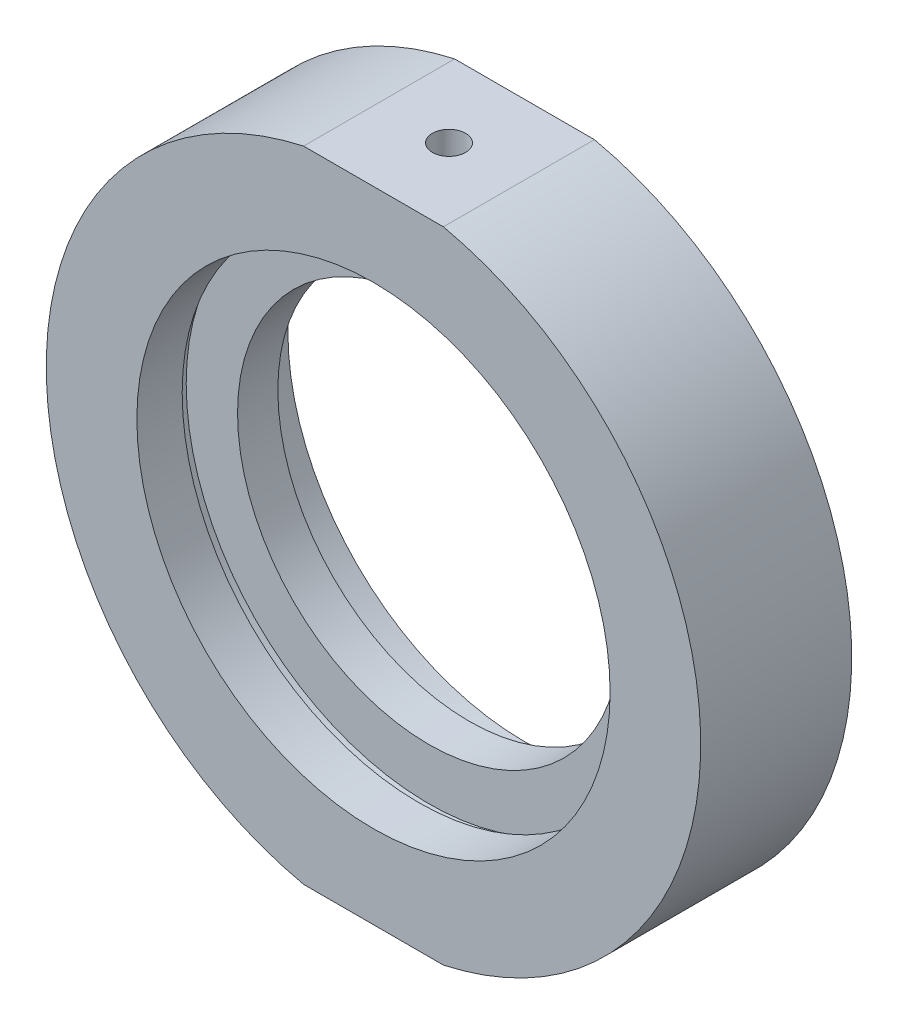
from build123d import *

# Parameters (mm, degrees)
SKETCH_2_W             = 64.02174429
SKETCH_2_H             = 9.248919907
CUT_EXTRUDE_1_DEPTH    = 49
HOLE_WIZARD_M4_2_D     = 3.3
HOLE_WIZARD_M4_2_DEPTH = 5.5
HOLE_WIZARD_M4_2_TIP   = 0.991420021
HOLE_WIZARD_M6_2_D     = 5
HOLE_WIZARD_M6_2_DEPTH = 5.5
HOLE_WIZARD_M6_2_TIP   = 1.502151548


with BuildPart() as part:
    # 草图1 → 旋转1 (revolve)
    with BuildSketch(Plane(origin=(0, 0, 0), x_dir=(1, 0, 0), z_dir=(0, 1, 0)), mode=Mode.PRIVATE) as revolve_1_sk:
        Polygon((32.5, 7.5), (32.5, -7.5), (23.5, -7.5), (23.5, -3), (24.1, -3), (24.1, -2), (19, -2), (19, 2), (24.1, 2), (24.1, 3), (23.5, 3), (23.5, 7.5), align=None)
    revolve(revolve_1_sk.sketch.rotate(Axis((0, 0, -31.9390681), (0, 0, 1)), 180), axis=Axis((0, 0, -31.9390681), (0, 0, 1)))  # turned: the seam where the file's is

    # 草图2 → 切除-拉伸1 (cut)
    with BuildSketch(Plane.XY.offset(7.5)):
        with Locations((-1.141100508, 36.374459954)):
            Rectangle(SKETCH_2_W, SKETCH_2_H)
        with Locations((-1.141100508, -36.374459954)):
            Rectangle(SKETCH_2_W, SKETCH_2_H)
    extrude(amount=-CUT_EXTRUDE_1_DEPTH, mode=Mode.SUBTRACT)

    # M4 螺纹孔2
    with Locations(Plane(origin=(0, 31.75, 0), x_dir=(1, 0, 0), z_dir=(0, 1, 0))):
        with Locations((0, 0)):
            Hole(HOLE_WIZARD_M4_2_D / 2, depth=HOLE_WIZARD_M4_2_DEPTH)
            with Locations((0, 0, -(HOLE_WIZARD_M4_2_DEPTH + HOLE_WIZARD_M4_2_TIP / 2))):  # 118° drill point
                Cone(0, HOLE_WIZARD_M4_2_D / 2, HOLE_WIZARD_M4_2_TIP, mode=Mode.SUBTRACT)

    # M6 螺纹孔2
    with Locations(Plane(origin=(0, -31.75, 0), x_dir=(-1, 0, 0), z_dir=(0, -1, 0))):
        with Locations((0, 0)):
            Hole(HOLE_WIZARD_M6_2_D / 2, depth=HOLE_WIZARD_M6_2_DEPTH)
            with Locations((0, 0, -(HOLE_WIZARD_M6_2_DEPTH + HOLE_WIZARD_M6_2_TIP / 2))):  # 118° drill point
                Cone(0, HOLE_WIZARD_M6_2_D / 2, HOLE_WIZARD_M6_2_TIP, mode=Mode.SUBTRACT)


solid = part.part
